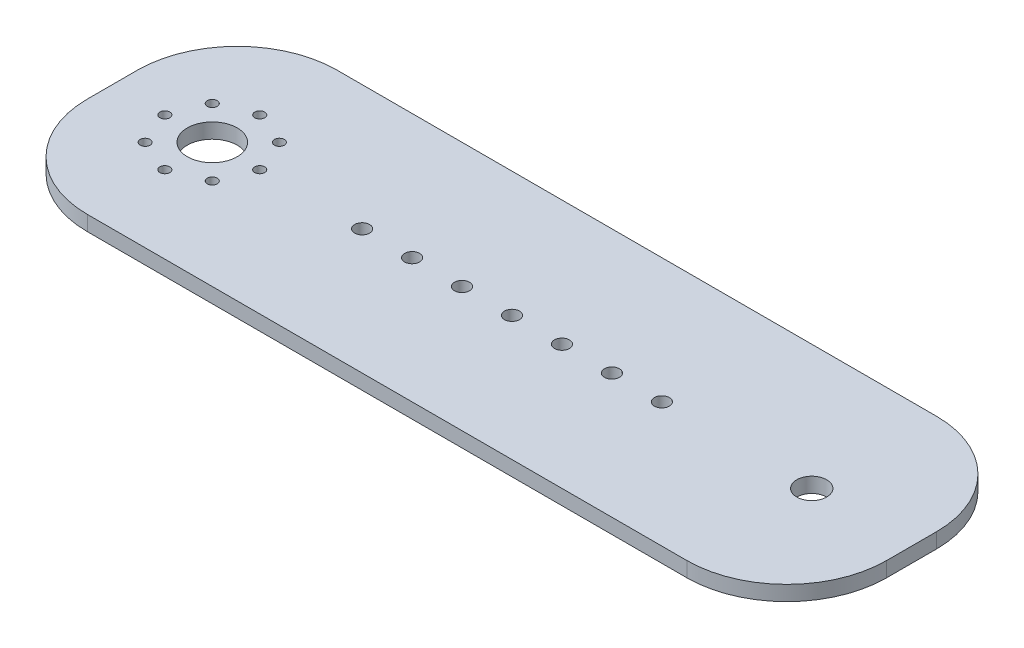
from build123d import *

# Parameters (mm, degrees)
SKETCH1_W           = 160
SKETCH1_H           = 50
BOSS_EXTRUDE1_DEPTH = 3
FILLET1_R           = 20
SKETCH2_R           = 5
CUT_EXTRUDE1_DEPTH  = 4
SKETCH3_R           = 1
CUT_EXTRUDE2_DEPTH  = 4
CIRPATTERN1_COUNT   = 8
SKETCH4_R           = 3
CUT_EXTRUDE3_DEPTH  = 4
SKETCH5_R           = 1.5
CUT_EXTRUDE4_DEPTH  = 4
LPATTERN1_COUNT     = 4
LPATTERN1_PITCH     = 10
LPATTERN1_COL_COUNT = 4
LPATTERN1_COL_PITCH = 10


with BuildPart() as part:
    # Sketch1 → Boss-Extrude1 (new body)
    with BuildSketch(Plane(origin=(0, 0, 0), x_dir=(1, 0, 0), z_dir=(0, 1, 0))):
        Rectangle(SKETCH1_W, SKETCH1_H)
    extrude(amount=BOSS_EXTRUDE1_DEPTH)

    # Fillet1
    fillet1_edges = [part.edges().sort_by_distance(p)[0] for p in [
        (80, 1.5, 25),
        (-80, 1.5, 25),
        (-80, 1.5, -25),
        (80, 1.5, -25),
    ]]
    fillet(fillet1_edges, radius=FILLET1_R)

    # Sketch2 → Cut-Extrude1 (cut, through all)
    with BuildSketch(Plane(origin=(0, 3, 0), x_dir=(1, 0, 0), z_dir=(0, 1, 0))):
        with Locations((-60, 0)):
            Circle(SKETCH2_R)
    extrude(amount=-CUT_EXTRUDE1_DEPTH, mode=Mode.SUBTRACT)

    # Sketch3 → Cut-Extrude2 (cut, through all)
    with BuildSketch(Plane(origin=(0, 3, 0), x_dir=(1, 0, 0), z_dir=(0, 1, 0))):
        with Locations((-50.5, 0)):
            Circle(SKETCH3_R)
    cut_extrude2 = extrude(amount=-CUT_EXTRUDE2_DEPTH, mode=Mode.SUBTRACT)

    # CirPattern1: Cut-Extrude2 ×8 about axis
    cirpattern1_axis = Axis((-60, 0, 0), (0, 1, 0))
    for i in range(1, CIRPATTERN1_COUNT):
        add(cut_extrude2.rotate(cirpattern1_axis, i * 360 / CIRPATTERN1_COUNT), mode=Mode.SUBTRACT)

    # Sketch4 → Cut-Extrude3 (cut, through all)
    with BuildSketch(Plane(origin=(0, 3, 0), x_dir=(1, 0, 0), z_dir=(0, 1, 0))):
        with Locations((60, 0)):
            Circle(SKETCH4_R)
    extrude(amount=-CUT_EXTRUDE3_DEPTH, mode=Mode.SUBTRACT)

    # Sketch5 → Cut-Extrude4 (cut, through all)
    with BuildSketch(Plane(origin=(0, 3, 0), x_dir=(1, 0, 0), z_dir=(0, 1, 0))):
        Circle(SKETCH5_R)
    cut_extrude4 = extrude(amount=-CUT_EXTRUDE4_DEPTH, mode=Mode.SUBTRACT)

    # LPattern1: Cut-Extrude4 ×4
    with Locations(*[(i * LPATTERN1_PITCH, 0, 0) for i in range(1, LPATTERN1_COUNT)]):
        add(cut_extrude4, mode=Mode.SUBTRACT)

    # LPattern1 col: Cut-Extrude4 ×4
    with Locations(*[(-i * LPATTERN1_COL_PITCH, 0, 0) for i in range(1, LPATTERN1_COL_COUNT)]):
        add(cut_extrude4, mode=Mode.SUBTRACT)


solid = part.part
